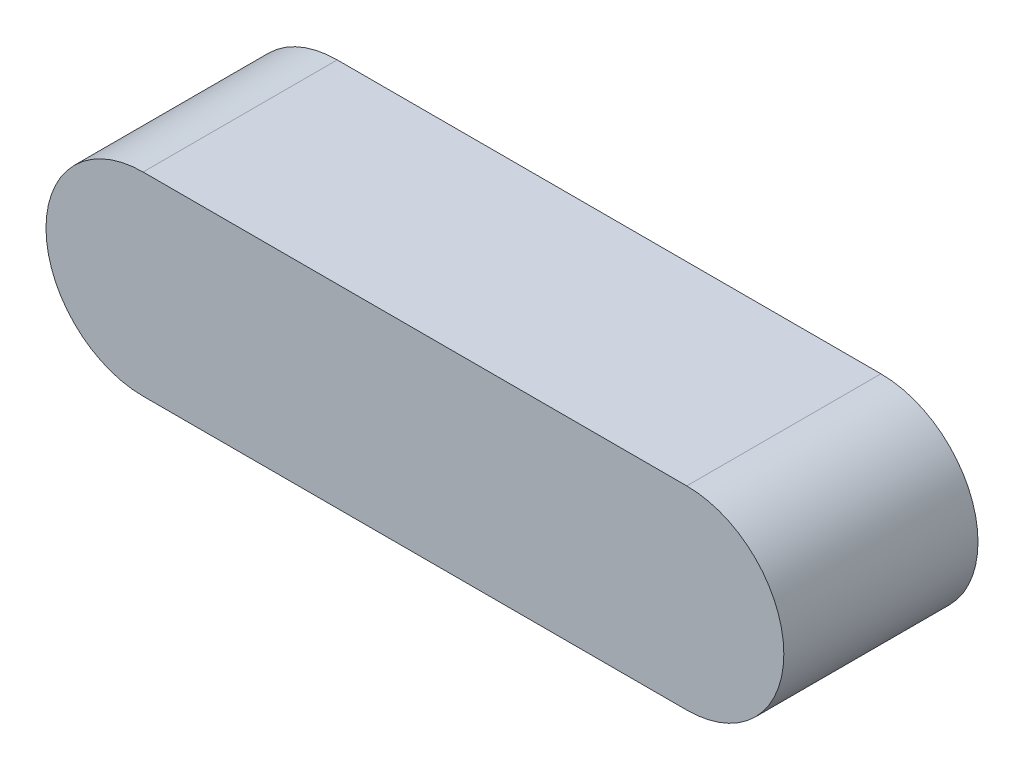
from build123d import *

# Parameters (mm, degrees)
SKETCH_1_W      = 14
SKETCH_1_H      = 5
EXTRUDE_1_DEPTH = 5


with BuildPart() as part:
    # 草图1 → 凸台-拉伸1 (new body)
    with BuildSketch(Plane.XY):
        with BuildLine():
            Line((-7, 2.5), (-7, -2.5))
            ThreePointArc((-7, -2.5), (-9.5, 0), (-7, 2.5))
        make_face()
        Rectangle(SKETCH_1_W, SKETCH_1_H)
        with BuildLine():
            ThreePointArc((7, 2.5), (9.5, 0), (7, -2.5))
            Line((7, -2.5), (7, 2.5))
        make_face()
    extrude(amount=EXTRUDE_1_DEPTH)


solid = part.part
